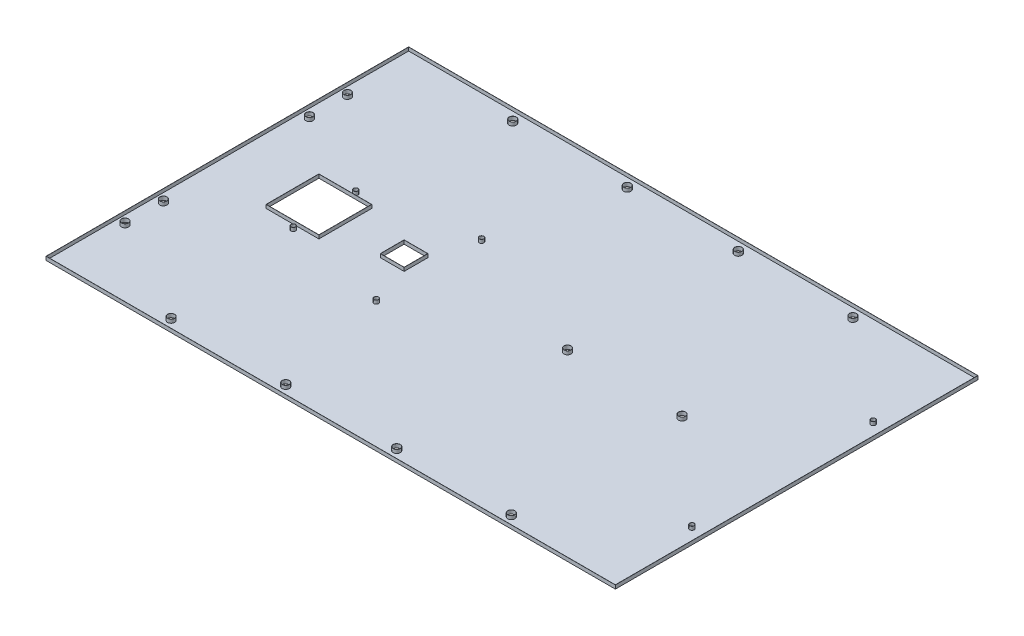
from build123d import *

# Parameters (mm, degrees)
SKETCH1_W                    = 199.39
SKETCH1_H                    = 127
BOSS_EXTRUDE1_DEPTH          = 2.54
F_11_0_191_DIAMETER_HOLE1_D  = 4.8514
F_11_0_191_DIAMETER_HOLE2_D  = 4.8514
SKETCH8_W                    = 36.83
SKETCH8_H                    = 18.415
SKETCH8_W_2                  = 16.51
SKETCH8_H_2                  = 8.255
CUT_EXTRUDE1_DEPTH           = 2.54
F_11_0_191_DIAMETER_HOLE3_D  = 4.8514
F_31_0_12_DIAMETER_HOLE2_D   = 3.048
F_31_0_12_DIAMETER_HOLE3_D   = 3.048
F_1_8_0_125_DIAMETER_HOLE1_D = 3.048
SHELL1_T                     = -0.1016


with BuildPart() as part:
    # Sketch1 → Boss-Extrude1 (new body)
    with BuildSketch(Plane(origin=(0, 0, 0), x_dir=(1, 0, 0), z_dir=(0, 1, 0))):
        with Locations((-99.695, 0)):
            Rectangle(SKETCH1_W, SKETCH1_H)
        with Locations((99.695, 0)):
            Rectangle(SKETCH1_W, SKETCH1_H)
    boss_extrude1 = extrude(amount=BOSS_EXTRUDE1_DEPTH)

    # #11 (0.191) Diameter Hole1 (through all)
    with Locations(Plane(origin=(0, 2.54, 0), x_dir=(1, 0, 0), z_dir=(0, 1, 0))):
        with Locations((-193.167, -14.4018), (-193.04, 12.3444)):
            f_11_0_191_diameter_hole1 = Hole(F_11_0_191_DIAMETER_HOLE1_D / 2)

    # #11 (0.191) Diameter Hole2 (through all)
    with Locations(Plane(origin=(0, 2.54, 0), x_dir=(1, 0, 0), z_dir=(0, 1, 0))):
        with Locations((-119.126, -56.127777467), (-38.862, -56.127777467), (38.862, -56.127777467), (119.126, -56.127777467)):
            f_11_0_191_diameter_hole2 = Hole(F_11_0_191_DIAMETER_HOLE2_D / 2)

    # Sketch8 → Cut-Extrude1 (cut)
    with BuildSketch(Plane(origin=(0, 2.54, 0), x_dir=(1, 0, 0), z_dir=(0, 1, 0))):
        with Locations((-135.255, 54.2925)):
            Rectangle(SKETCH8_W, SKETCH8_H)
        with Locations((-75.565, 59.3725)):
            Rectangle(SKETCH8_W_2, SKETCH8_H_2)
    cut_extrude1 = extrude(amount=-CUT_EXTRUDE1_DEPTH, mode=Mode.SUBTRACT)

    # Mirror6: Boss-Extrude1, #11 (0.191) Diameter Hole1, #11 (0.191) Diameter Hole2, Cut-Extrude1 across plane
    add(boss_extrude1.mirror(Plane(origin=(0, 2.54, -63.5), x_dir=(1, 0, 0), z_dir=(0, 0, -1))))
    add(f_11_0_191_diameter_hole1.mirror(Plane(origin=(0, 2.54, -63.5), x_dir=(1, 0, 0), z_dir=(0, 0, -1))), mode=Mode.SUBTRACT)
    add(f_11_0_191_diameter_hole2.mirror(Plane(origin=(0, 2.54, -63.5), x_dir=(1, 0, 0), z_dir=(0, 0, -1))), mode=Mode.SUBTRACT)
    add(cut_extrude1.mirror(Plane(origin=(0, 2.54, -63.5), x_dir=(1, 0, 0), z_dir=(0, 0, -1))), mode=Mode.SUBTRACT)

    # #11 (0.191) Diameter Hole3 (through all)
    with Locations(Plane(origin=(0, 2.54, 0), x_dir=(1, 0, 0), z_dir=(0, 1, 0))):
        with Locations((119.126, 63.5), (38.862, 63.5)):
            Hole(F_11_0_191_DIAMETER_HOLE3_D / 2)

    # #31 (0.12) Diameter Hole2 (through all)
    with Locations(Plane(origin=(0, 2.54, 0), x_dir=(1, 0, 0), z_dir=(0, 1, 0))):
        with Locations((-131.318, 41.656), (-131.318, 85.344)):
            Hole(F_31_0_12_DIAMETER_HOLE2_D / 2)

    # #31 (0.12) Diameter Hole3 (through all)
    with Locations(Plane(origin=(0, 2.54, 0), x_dir=(1, 0, 0), z_dir=(0, 1, 0))):
        with Locations((-58.166, 100.33), (-58.166, 26.67)):
            Hole(F_31_0_12_DIAMETER_HOLE3_D / 2)

    # 1/8 (0.125) Diameter Hole1 (through all)
    with Locations(Plane(origin=(0, 2.54, 0), x_dir=(1, 0, 0), z_dir=(0, 1, 0))):
        with Locations((189.484, 0), (189.484, 127)):
            Hole(F_1_8_0_125_DIAMETER_HOLE1_D / 2)

    # Shell1
    shell1_openings = [part.faces().sort_by_distance(p)[0] for p in [
        (189.484, 2.54, 1.524),
    ]]
    offset(amount=SHELL1_T, openings=shell1_openings, kind=Kind.INTERSECTION)


solid = part.part
